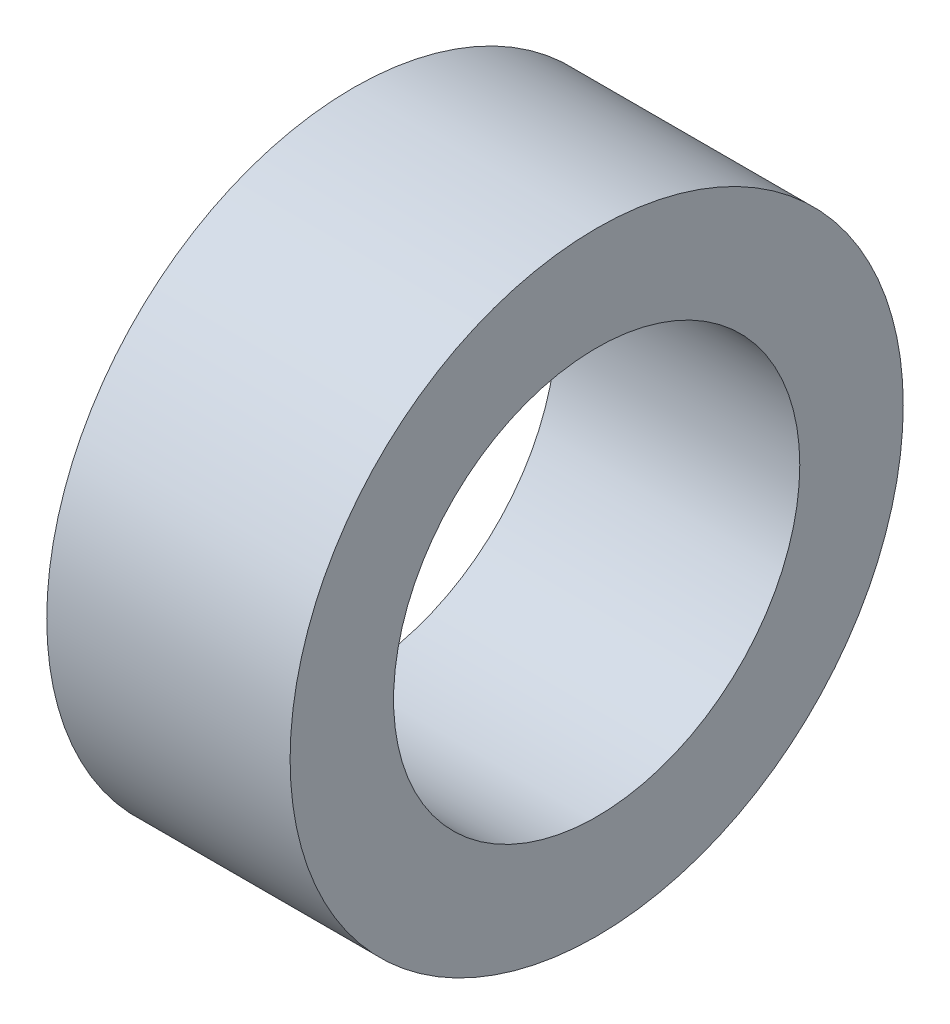
from build123d import *

# Parameters (mm, degrees)
SKETCH1_R           = 4
SKETCH1_R_2         = 2.65
BOSS_EXTRUDE1_DEPTH = 3.175


with BuildPart() as part:
    # Sketch1 → Boss-Extrude1 (new body)
    with BuildSketch(Plane(origin=(0, 0, 0), x_dir=(0, 0, -1), z_dir=(1, 0, 0))):
        Circle(SKETCH1_R)
        Circle(SKETCH1_R_2, mode=Mode.SUBTRACT)
    extrude(amount=BOSS_EXTRUDE1_DEPTH)


solid = part.part
